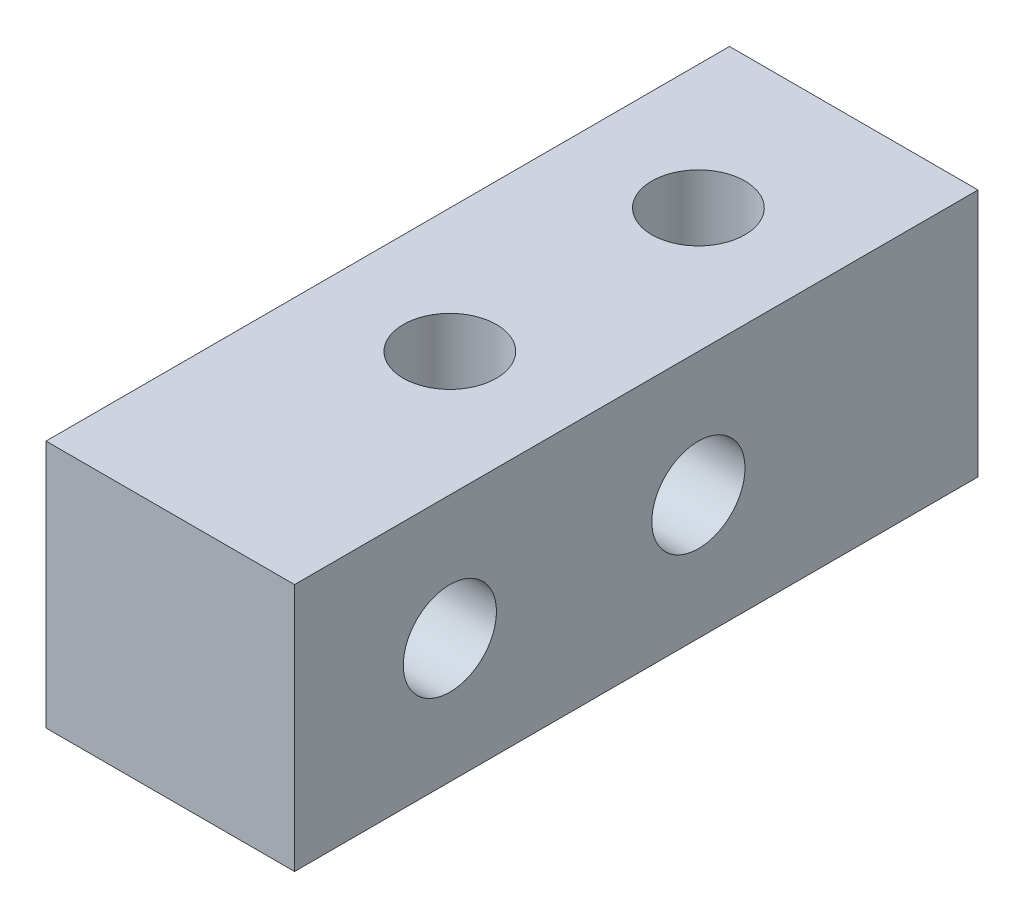
from build123d import *

# Parameters (mm, degrees)
SKETCH_1_W          = 8
SKETCH_1_H          = 8
EXTRUDE_1_DEPTH     = 22
SKETCH_2_R          = 1.5
CUT_EXTRUDE_1_DEPTH = 9
SKETCH_3_R          = 1.5
CUT_EXTRUDE_2_DEPTH = 9


with BuildPart() as part:
    # 草图1 → 凸台-拉伸1 (new body)
    with BuildSketch(Plane.XY):
        Rectangle(SKETCH_1_W, SKETCH_1_H)
    extrude(amount=EXTRUDE_1_DEPTH)

    # 草图2 → 切除-拉伸1 (cut, through all)
    with BuildSketch(Plane(origin=(0, 4, 0), x_dir=(1, 0, 0), z_dir=(0, 1, 0))):
        with Locations((0, -5)):
            Circle(SKETCH_2_R)
        with Locations((0, -13)):
            Circle(SKETCH_2_R)
    extrude(amount=-CUT_EXTRUDE_1_DEPTH, mode=Mode.SUBTRACT)

    # 草图3 → 切除-拉伸2 (cut, through all)
    with BuildSketch(Plane(origin=(4, 0, 0), x_dir=(0, 0, -1), z_dir=(1, 0, 0))):
        with Locations((-17, 0)):
            Circle(SKETCH_3_R)
        with Locations((-9, 0)):
            Circle(SKETCH_3_R)
    extrude(amount=-CUT_EXTRUDE_2_DEPTH, mode=Mode.SUBTRACT)


solid = part.part
